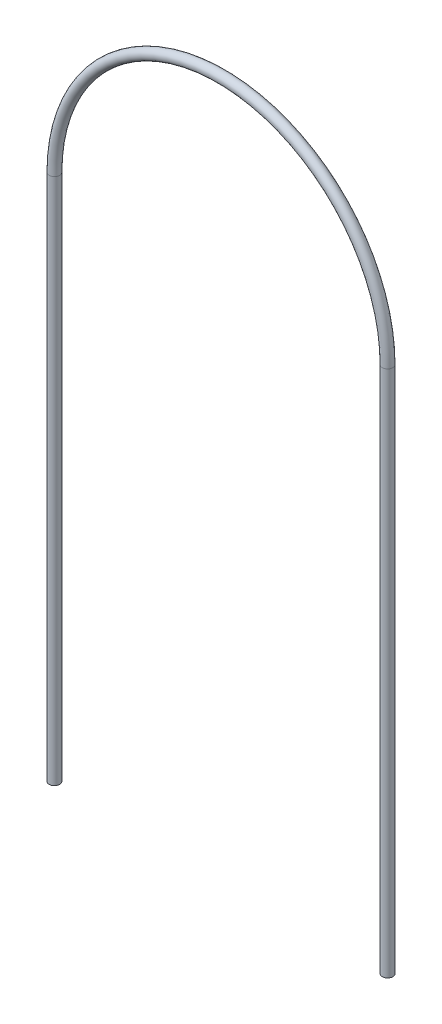
from build123d import *

# Parameters (mm, degrees)
SKETCH1_R           = 2.413
REVOLVE1_ANGLE      = 180
SKETCH2_R           = 2.413
BOSS_EXTRUDE1_DEPTH = 241.3
SKETCH3_R           = 2.413
BOSS_EXTRUDE2_DEPTH = 241.3


with BuildPart() as part:
    # Sketch1 → Revolve1 (revolve)
    with BuildSketch(Plane.XZ.offset(-215.9)):
        with Locations((152.4, 0)):
            Circle(SKETCH1_R)
    revolve(axis=Axis((76.2, 215.9, 2.413), (0, 0, 1)), revolution_arc=REVOLVE1_ANGLE)

    # Sketch2 → Boss-Extrude1 (add)
    with BuildSketch(Plane.XZ.offset(-215.9)):
        with Locations((152.4, 0)):
            Circle(SKETCH2_R)
    extrude(amount=BOSS_EXTRUDE1_DEPTH)

    # Sketch3 → Boss-Extrude2 (add)
    with BuildSketch(Plane.XZ.offset(-215.9)):
        Circle(SKETCH3_R)
    extrude(amount=BOSS_EXTRUDE2_DEPTH)


solid = part.part
